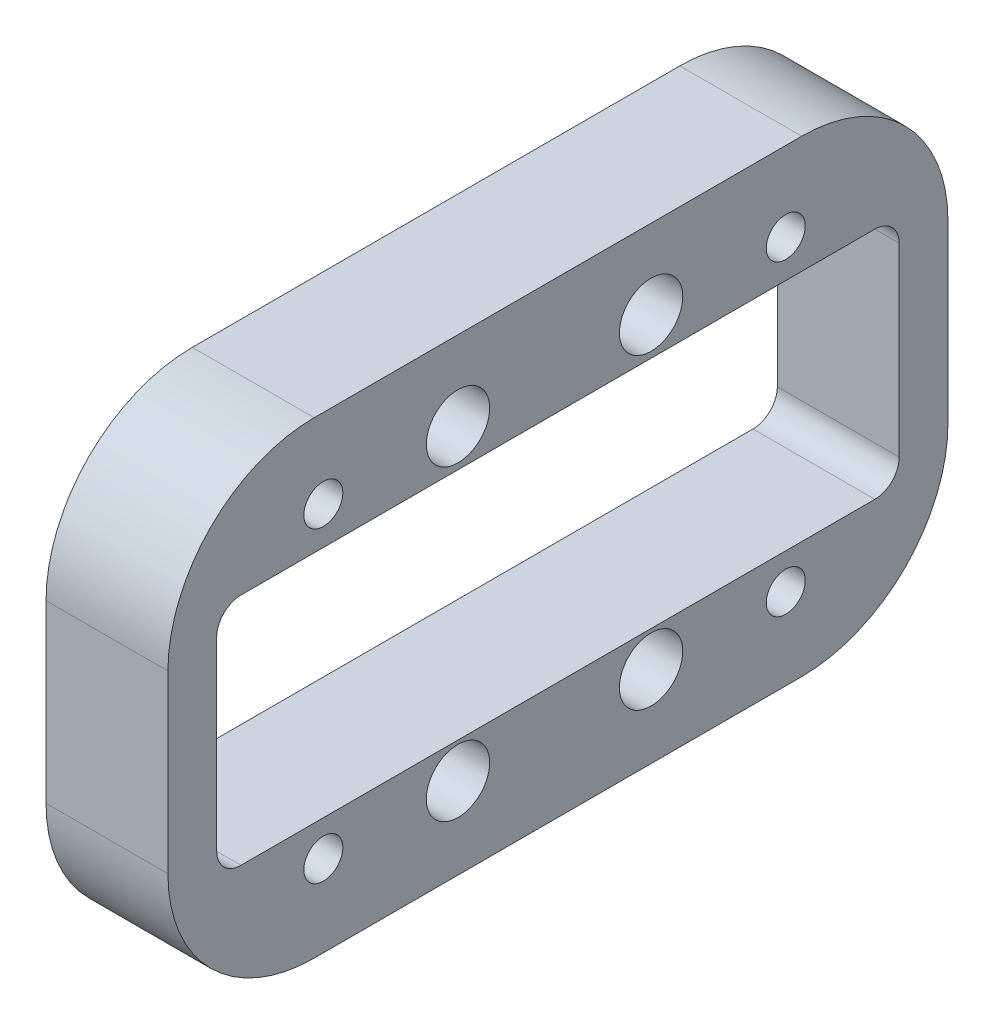
from build123d import *

# Parameters (mm, degrees)
SKETCH_1_W          = 160
SKETCH_1_H          = 96
SKETCH_1_R          = 4
SKETCH_1_W_2        = 140
SKETCH_1_H_2        = 48
EXTRUDE_1_DEPTH     = 25
FILLET_1_R          = 30
FILLET_2_R          = 5
SKETCH_11_R         = 6.498169544
SKETCH_11_R_2       = 6.5
CUT_EXTRUDE_1_DEPTH = 15


with BuildPart() as part:
    # 草图1 → 凸台-拉伸1 (new body)
    with BuildSketch(Plane(origin=(0, 0, 0), x_dir=(0, 0, -1), z_dir=(1, 0, 0))):
        with Locations((18.05845234, 14.323348887)):
            Rectangle(SKETCH_1_W, SKETCH_1_H)
        with Locations((-2.443633142, 46.063348887)):
            Circle(SKETCH_1_R, mode=Mode.SUBTRACT)
        with Locations((37.163019963, 46.063348887)):
            Circle(SKETCH_1_R, mode=Mode.SUBTRACT)
        with Locations((-2.443633142, -16.944440743)):
            Circle(SKETCH_1_R, mode=Mode.SUBTRACT)
        with Locations((37.163019963, -16.944440743)):
            Circle(SKETCH_1_R, mode=Mode.SUBTRACT)
        with Locations((64.784581693, 46.063348887)):
            Circle(SKETCH_1_R, mode=Mode.SUBTRACT)
        with Locations((-30.063633142, -16.944440743)):
            Circle(SKETCH_1_R, mode=Mode.SUBTRACT)
        with Locations((64.784581693, -16.944440743)):
            Circle(SKETCH_1_R, mode=Mode.SUBTRACT)
        with Locations((-30.063633142, 46.063348887)):
            Circle(SKETCH_1_R, mode=Mode.SUBTRACT)
        with Locations((18.05845234, 14.323348887)):
            Rectangle(SKETCH_1_W_2, SKETCH_1_H_2, mode=Mode.SUBTRACT)
    extrude(amount=-EXTRUDE_1_DEPTH)

    # 圆角1
    fillet_1_edges = [part.edges().sort_by_distance(p)[0] for p in [
        (-12.5, 62.323348887, 61.94154766),
        (-12.5, 62.323348887, -98.05845234),
        (-12.5, -33.676651113, -98.05845234),
        (-12.5, -33.676651113, 61.94154766),
    ]]
    fillet(fillet_1_edges, radius=FILLET_1_R)

    # 圆角2
    fillet_2_edges = [part.edges().sort_by_distance(p)[0] for p in [
        (-12.5, -9.676651113, 51.94154766),
        (-12.5, 38.323348887, 51.94154766),
        (-12.5, 38.323348887, -88.05845234),
        (-12.5, -9.676651113, -88.05845234),
    ]]
    fillet(fillet_2_edges, radius=FILLET_2_R)

    # 草图11 → 切除-拉伸1 (cut)
    with BuildSketch(Plane(origin=(0, 0, 0), x_dir=(0, 0, -1), z_dir=(1, 0, 0))):
        with Locations((37.163019963, 46.063348887)):
            Circle(SKETCH_11_R)
        with Locations((-2.443633142, 46.063348887)):
            Circle(SKETCH_11_R_2)
        with Locations((37.163019963, -16.944440743)):
            Circle(SKETCH_11_R_2)
        with Locations((-2.443633142, -16.944440743)):
            Circle(SKETCH_11_R_2)
    extrude(amount=-CUT_EXTRUDE_1_DEPTH, mode=Mode.SUBTRACT)


solid = part.part
